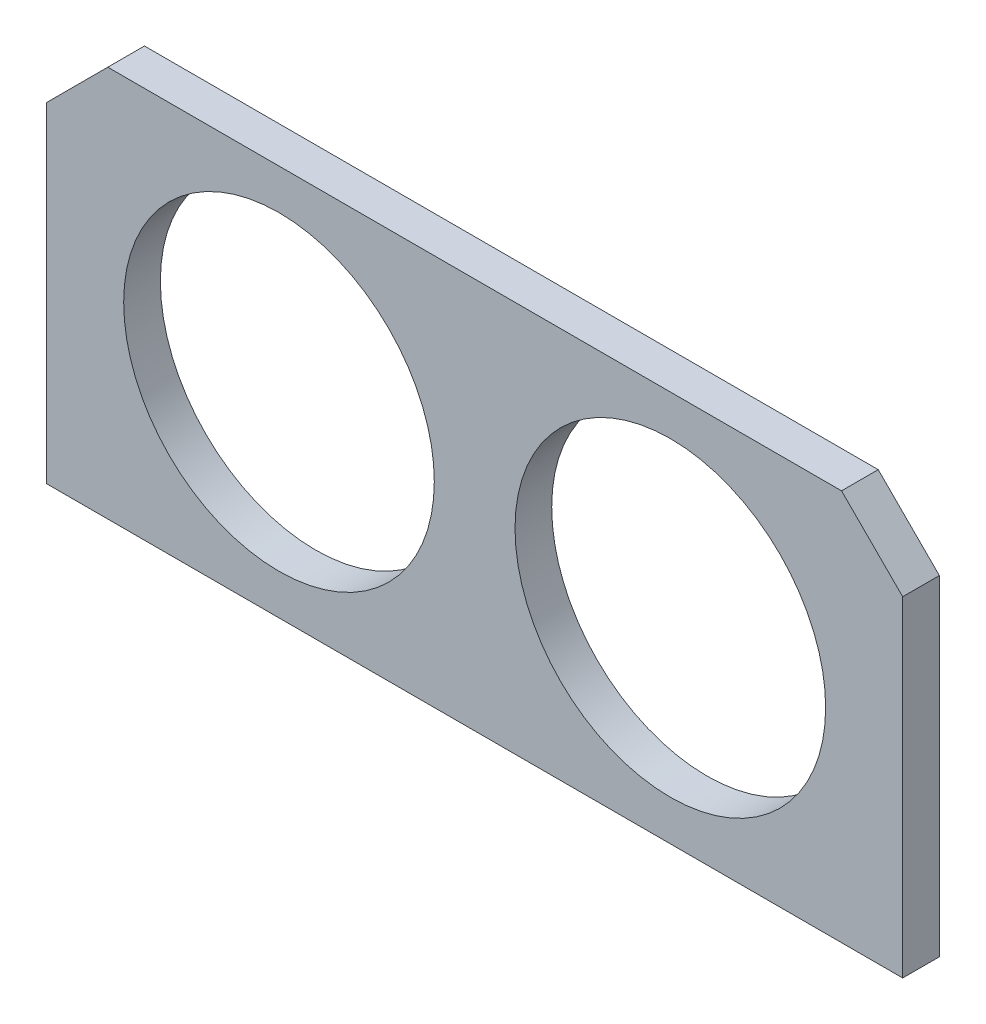
from build123d import *

# Parameters (mm, degrees)
SKETCH1_R           = 12.7
BOSS_EXTRUDE1_DEPTH = 3
CHAMFER1_SIZE       = 5


with BuildPart() as part:
    # Sketch1 → Boss-Extrude1 (new body)
    with BuildSketch(Plane.XY):
        Polygon((-78.698002714, 24.844630316), (-78.698002714, 40.844630316), (-59.698002714, 40.844630316), (-8.698002714, 40.844630316), (-8.698002714, 8.844630316), (-59.698002714, 8.844630316), (-78.698002714, 8.844630316), align=None)
        with Locations((-59.698002714, 24.844630316)):
            Circle(SKETCH1_R, mode=Mode.SUBTRACT)
        with Locations((-27.698002714, 24.844630316)):
            Circle(SKETCH1_R, mode=Mode.SUBTRACT)
    extrude(amount=BOSS_EXTRUDE1_DEPTH)

    # Chamfer1
    chamfer1_edges = [part.edges().sort_by_distance(p)[0] for p in [
        (-8.698002714, 40.844630316, 1.5),
        (-78.698002714, 40.844630316, 1.5),
    ]]
    chamfer(chamfer1_edges, length=CHAMFER1_SIZE)


solid = part.part
